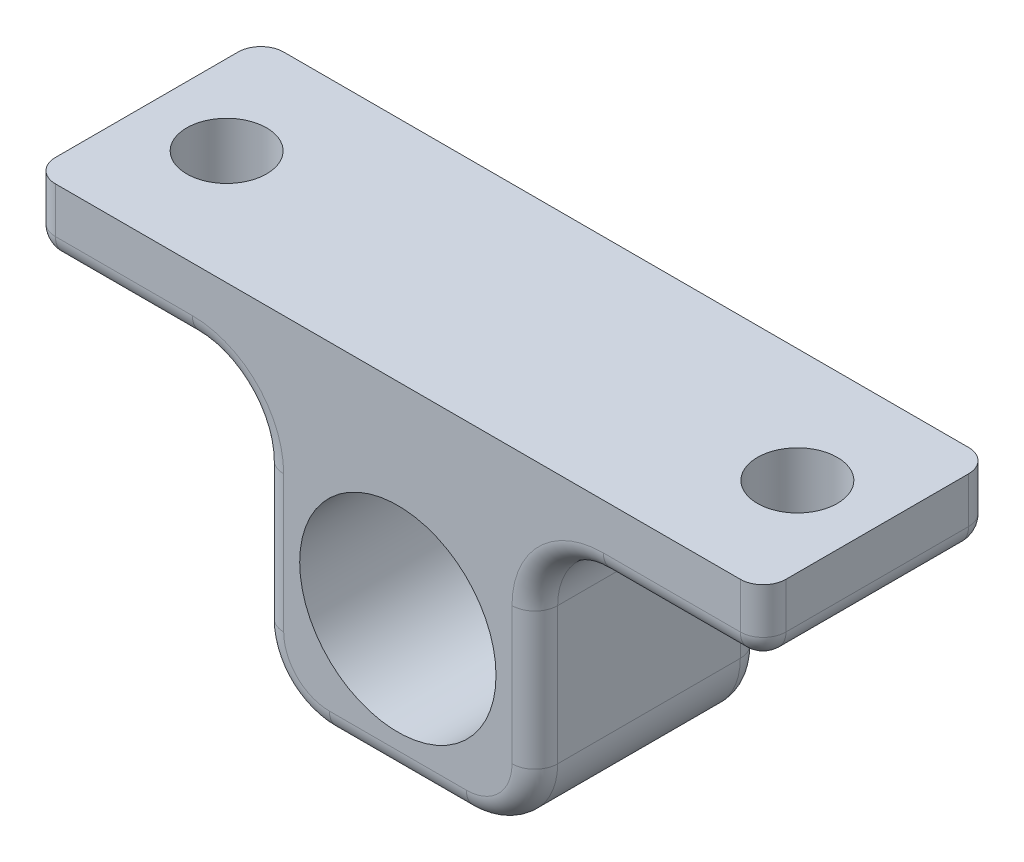
from build123d import *

# Parameters (mm, degrees)
SKETCH_1_W          = 10
SKETCH_1_H          = 3
EXTRUDE_1_DEPTH     = 10
SKETCH_2_R          = 4.3
CUT_EXTRUDE_1_DEPTH = 11
SKETCH_3_R          = 1.75
CUT_EXTRUDE_2_DEPTH = 4
FILLET_1_R          = 3
FILLET_2_R          = 1


with BuildPart() as part:
    # ｽｹｯﾁ1 → ﾎﾞｽ - 押し出し1 (new body)
    with BuildSketch(Plane.XY):
        Polygon((7, 10), (1, 10), (1, -5), (7, -5), (7, 7), align=None)
        with Locations((12, 8.5)):
            Rectangle(SKETCH_1_W, SKETCH_1_H)
        Polygon((1, -5), (1, 10), (-5, 10), (-5, 7), (-5, -5), align=None)
        with Locations((-10, 8.5)):
            Rectangle(SKETCH_1_W, SKETCH_1_H)
    extrude(amount=EXTRUDE_1_DEPTH)

    # ｽｹｯﾁ2 → ｶｯﾄ - 押し出し1 (cut, through all)
    with BuildSketch(Plane(origin=(0, 0, 0), x_dir=(-1, 0, 0), z_dir=(0, 0, -1))):
        with Locations((-1, 1)):
            Circle(SKETCH_2_R)
    extrude(amount=-CUT_EXTRUDE_1_DEPTH, mode=Mode.SUBTRACT)

    # ｽｹｯﾁ3 → ｶｯﾄ - 押し出し2 (cut, through all)
    with BuildSketch(Plane.XZ.offset(-7)):
        with Locations((-11.5, 5)):
            Circle(SKETCH_3_R)
        with Locations((13.5, 5)):
            Circle(SKETCH_3_R)
    extrude(amount=-CUT_EXTRUDE_2_DEPTH, mode=Mode.SUBTRACT)

    # ﾌｨﾚｯﾄ1
    fillet_1_edges = [part.edges().sort_by_distance(p)[0] for p in [
        (7, -5, 5),
        (-5, -5, 5),
        (-5, 7, 5),
        (7, 7, 5),
    ]]
    fillet(fillet_1_edges, radius=FILLET_1_R)

    # ﾌｨﾚｯﾄ2
    fillet_2_edges = [part.edges().sort_by_distance(p)[0] for p in [
        (-15, 8.5, 0),
        (17, 8.5, 0),
        (17, 8.5, 10),
        (-15, 7, 5),
        (17, 7, 5),
        (-15, 8.5, 10),
        (-5, 1, 0),
        (-5, 1, 10),
        (-11.5, 7, 0),
        (-11.5, 7, 10),
        (13.5, 7, 0),
        (13.5, 7, 10),
        (7, 1, 0),
        (7, 1, 10),
        (1, -5, 0),
        (1, -5, 10),
        (6.121320344, -4.121320344, 0),
        (-4.121320344, -4.121320344, 0),
        (6.121320344, -4.121320344, 10),
        (-4.121320344, -4.121320344, 10),
        (-5.878679656, 6.121320344, 0),
        (-5.878679656, 6.121320344, 10),
        (7.878679656, 6.121320344, 0),
        (7.878679656, 6.121320344, 10),
    ]]
    fillet(fillet_2_edges, radius=FILLET_2_R)


solid = part.part
